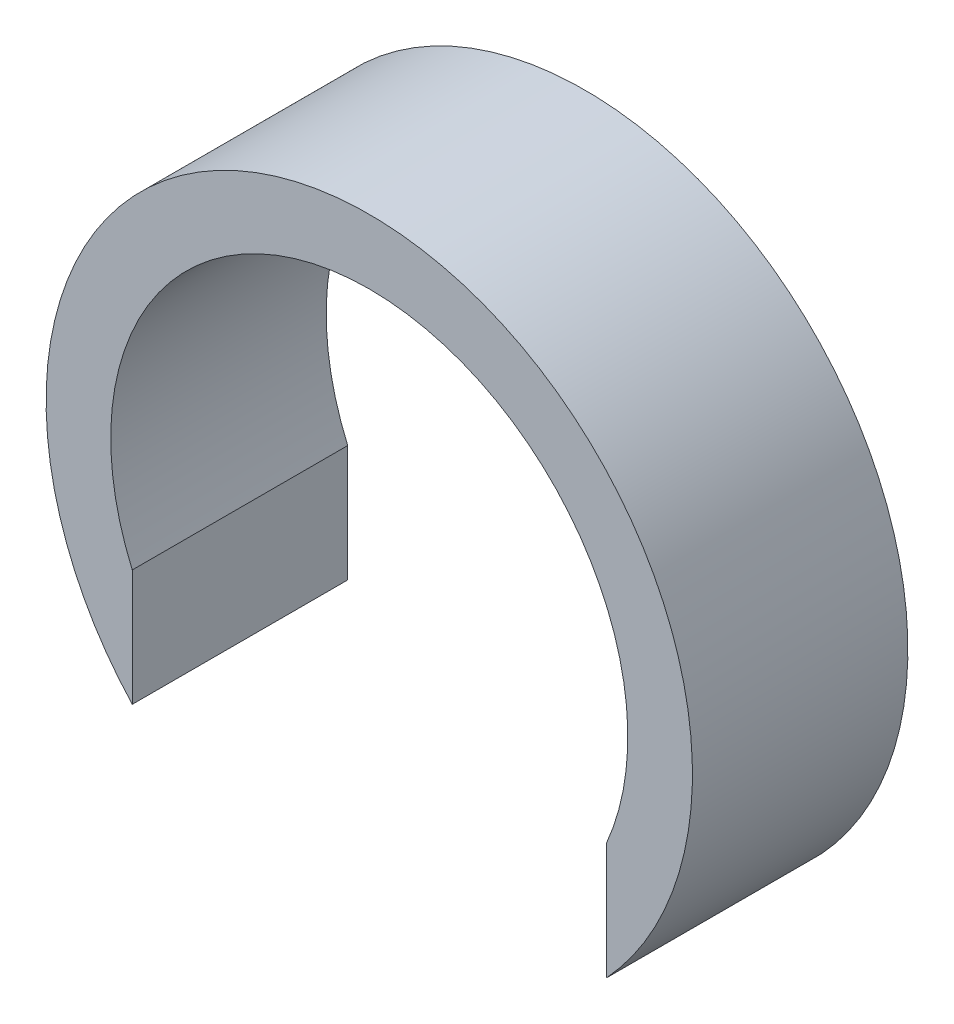
from build123d import *

# Parameters (mm, degrees)
EXTRUDE_1_DEPTH = 5


with BuildPart() as part:
    # ｽｹｯﾁ1 → ﾎﾞｽ - 押し出し1 (new body)
    with BuildSketch(Plane.XY):
        with BuildLine():
            Line((5.5, -5.099019514), (5.5, -2.397915762))
            ThreePointArc((5.5, -2.397915762), (0, 6), (-5.5, -2.397915762))
            Line((-5.5, -2.397915762), (-5.5, -5.099019514))
            ThreePointArc((-5.5, -5.099019514), (0, 7.5), (5.5, -5.099019514))
        make_face()
    extrude(amount=EXTRUDE_1_DEPTH)


solid = part.part
